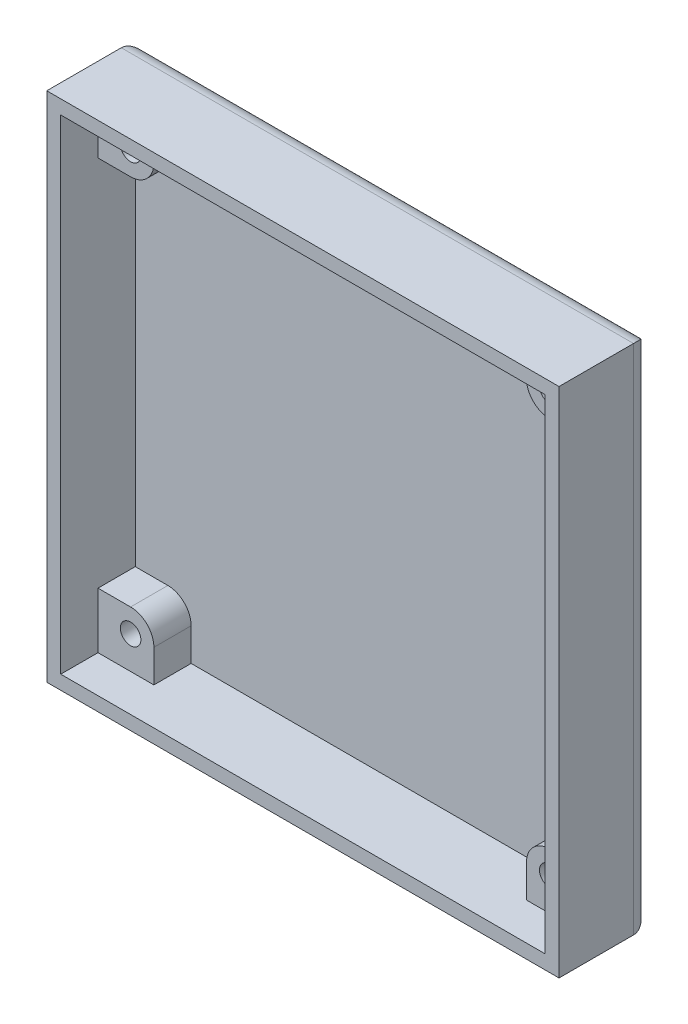
from build123d import *

# Parameters (mm, degrees)
SKETCH_1_W          = 55
SKETCH_1_H          = 55
EXTRUDE_1_DEPTH     = 10
SKETCH_2_W          = 52
SKETCH_2_H          = 52
CUT_EXTRUDE_1_DEPTH = 8
FILLET_1_R          = 2
SKETCH_3_R          = 2.5
EXTRUDE_2_DEPTH     = 4
SKETCH_5_R          = 1.1
CUT_EXTRUDE_2_DEPTH = 4
EXTRUDE_4_DEPTH     = 4
EXTRUDE_6_DEPTH     = 4


with BuildPart() as part:
    # 草图1 → 凸台-拉伸1 (new body)
    with BuildSketch(Plane.XY):
        Rectangle(SKETCH_1_W, SKETCH_1_H)
    extrude(amount=EXTRUDE_1_DEPTH)

    # 草图2 → 切除-拉伸1 (cut)
    with BuildSketch(Plane.XY.offset(10)):
        Rectangle(SKETCH_2_W, SKETCH_2_H)
    extrude(amount=-CUT_EXTRUDE_1_DEPTH, mode=Mode.SUBTRACT)

    # 圆角1
    fillet_1_edges = [part.edges().sort_by_distance(p)[0] for p in [
        (0, -27.5, 0),
        (-27.5, 0, 0),
        (0, 27.5, 0),
        (27.5, 0, 0),
    ]]
    fillet(fillet_1_edges, radius=FILLET_1_R)

    # 草图3 → 凸台-拉伸2 (add)
    with BuildSketch(Plane.XY.offset(2)):
        with Locations((-22.5, 22.5)):
            Circle(SKETCH_3_R)
        with Locations((22.5, 22.5)):
            Circle(SKETCH_3_R)
        with Locations((-22.5, -22.5)):
            Circle(SKETCH_3_R)
        with Locations((22.5, -22.5)):
            Circle(SKETCH_3_R)
    extrude(amount=EXTRUDE_2_DEPTH)

    # 草图5 → 切除-拉伸2 (cut)
    with BuildSketch(Plane.XY.offset(6)):
        with Locations((-22.5, -22.5)):
            Circle(SKETCH_5_R)
        with Locations((22.5, -22.5)):
            Circle(SKETCH_5_R)
        with Locations((-22.5, 22.5)):
            Circle(SKETCH_5_R)
        with Locations((22.5, 22.5)):
            Circle(SKETCH_5_R)
    extrude(amount=-CUT_EXTRUDE_2_DEPTH, mode=Mode.SUBTRACT)

    # 草图6 → 凸台-拉伸4 (add)
    with BuildSketch(Plane.XY.offset(2)):
        with BuildLine():
            ThreePointArc((-22.5, 20), (-25, 22.5), (-22.5, 25))
            Line((-22.5, 25), (-26, 25))
            Line((-26, 25), (-26, 20))
            Line((-26, 20), (-22.5, 20))
        make_face()
    extrude(amount=EXTRUDE_4_DEPTH)

    # 草图13 → 凸台-拉伸6 (add)
    with BuildSketch(Plane.XY.offset(2)):
        with BuildLine():
            ThreePointArc((-22.5, 25), (-20.732233047, 24.267766953), (-20, 22.5))
            Line((-20, 22.5), (-20, 26))
            Line((-20, 26), (-26, 26))
            Line((-26, 26), (-26, 25))
            Line((-26, 25), (-22.5, 25))
        make_face()
        with BuildLine():
            ThreePointArc((-20, -22.5), (-24.267766953, -24.267766953), (-22.5, -20))
            Line((-22.5, -20), (-26, -20))
            Line((-26, -20), (-26, -26))
            Line((-26, -26), (-20, -26))
            Line((-20, -26), (-20, -22.5))
        make_face()
        with BuildLine():
            Line((26, -20), (22.5, -20))
            ThreePointArc((22.5, -20), (24.267766953, -24.267766953), (20, -22.5))
            Line((20, -22.5), (20, -26))
            Line((20, -26), (26, -26))
            Line((26, -26), (26, -20))
        make_face()
        with BuildLine():
            Line((20, 26), (20, 22.5))
            ThreePointArc((20, 22.5), (24.267766953, 24.267766953), (22.5, 20))
            Line((22.5, 20), (26, 20))
            Line((26, 20), (26, 26))
            Line((26, 26), (20, 26))
        make_face()
    extrude(amount=EXTRUDE_6_DEPTH)


solid = part.part
